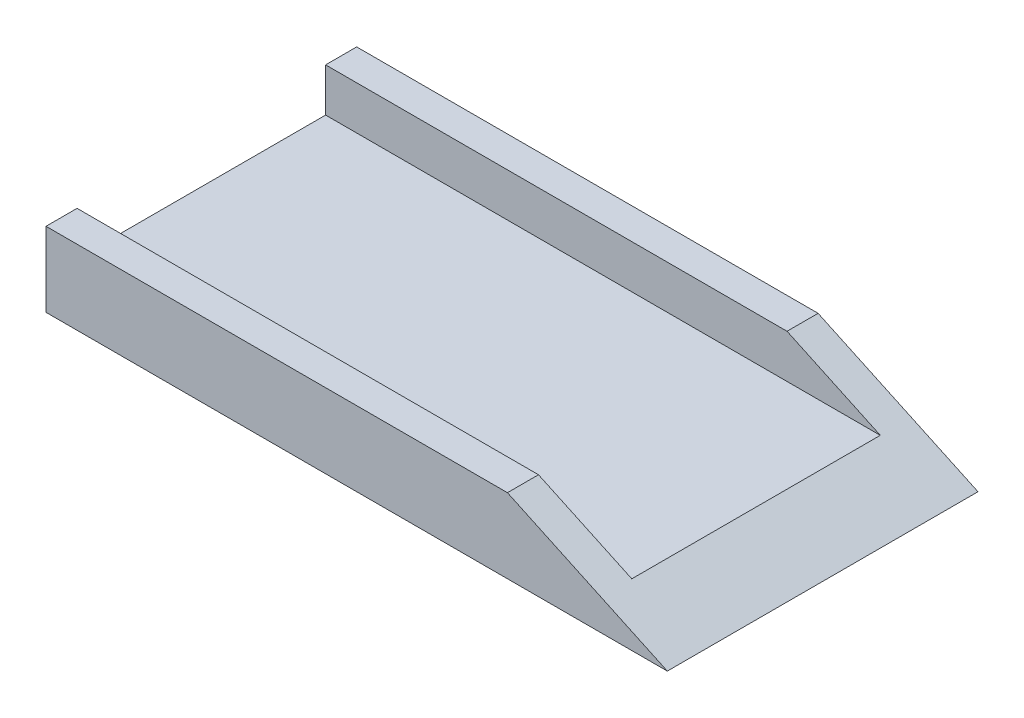
from build123d import *

# Parameters (mm, degrees)
SKETCH1_W           = 127
SKETCH1_H           = 6.35
BOSS_EXTRUDE1_DEPTH = 63.5
SKETCH2_W           = 127
SKETCH2_H           = 6.35
BOSS_EXTRUDE2_DEPTH = 8.89
CUT_EXTRUDE1_DEPTH  = 64.5


with BuildPart() as part:
    # Sketch1 → Boss-Extrude1 (new body)
    with BuildSketch(Plane.XY):
        Rectangle(SKETCH1_W, SKETCH1_H)
    extrude(amount=-BOSS_EXTRUDE1_DEPTH)

    # Sketch2 → Boss-Extrude2 (add)
    with BuildSketch(Plane(origin=(0, 3.175, 0), x_dir=(1, 0, 0), z_dir=(0, 1, 0))):
        with Locations((0, 60.325)):
            Rectangle(SKETCH2_W, SKETCH2_H)
        with Locations((0, 3.175)):
            Rectangle(SKETCH2_W, SKETCH2_H)
    extrude(amount=BOSS_EXTRUDE2_DEPTH)

    # Sketch3 → Cut-Extrude1 (cut, through all)
    with BuildSketch(Plane.XY):
        Polygon((63.5, -3.175), (30.817714531, 12.065), (41.55221838, 35.085217791), (74.234503848, 19.845217791), align=None)
    extrude(amount=-CUT_EXTRUDE1_DEPTH, mode=Mode.SUBTRACT)


solid = part.part
